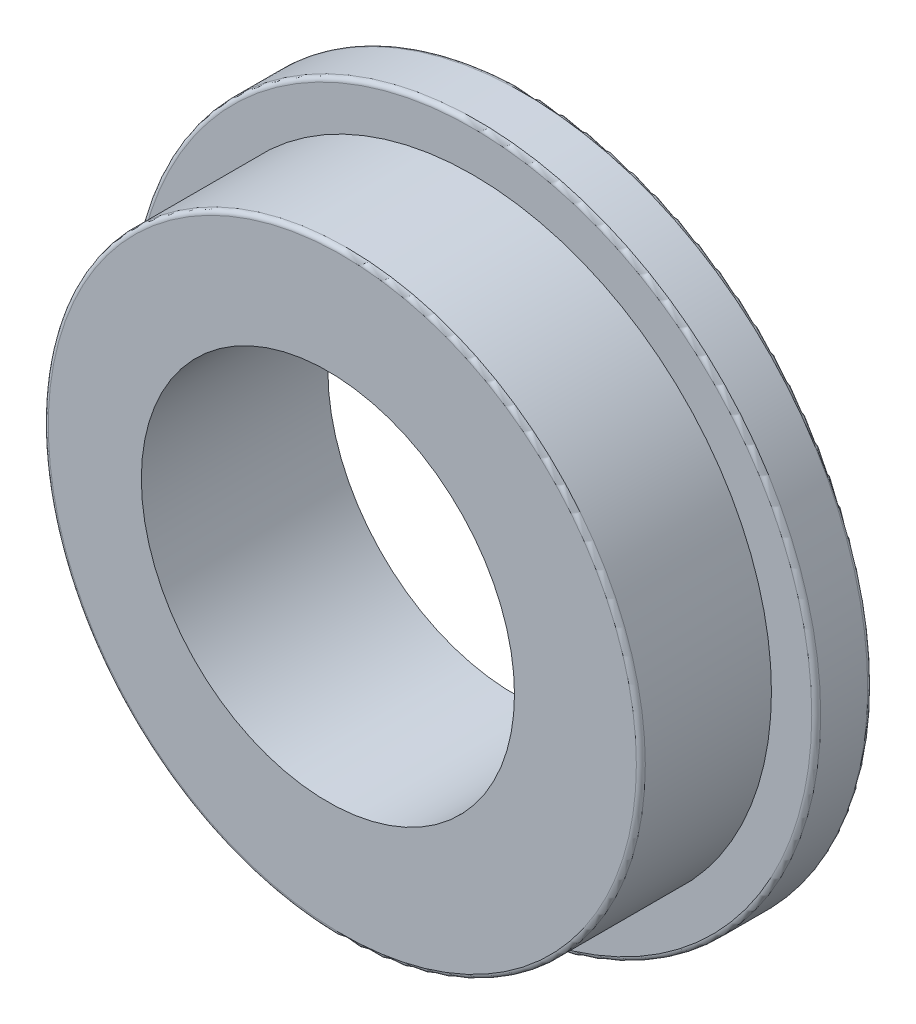
from build123d import *

# Parameters (mm, degrees)
SKETCH1_R           = 4.6
BOSS_EXTRUDE1_DEPTH = 0.75
SKETCH2_R           = 4
BOSS_EXTRUDE2_DEPTH = 1.75
SKETCH3_R           = 2.5
CUT_EXTRUDE1_DEPTH  = 3.5
FILLET1_R           = 0.06


with BuildPart() as part:
    # Sketch1 → Boss-Extrude1 (new body)
    with BuildSketch(Plane.XY):
        Circle(SKETCH1_R)
    extrude(amount=BOSS_EXTRUDE1_DEPTH)

    # Sketch2 → Boss-Extrude2 (add)
    with BuildSketch(Plane.XY.offset(0.75)):
        Circle(SKETCH2_R)
    extrude(amount=BOSS_EXTRUDE2_DEPTH)

    # Sketch3 → Cut-Extrude1 (cut, through all)
    with BuildSketch(Plane.XY.offset(2.5)):
        with Locations((-0.193142298, 0)):
            Circle(SKETCH3_R)
    extrude(amount=-CUT_EXTRUDE1_DEPTH, mode=Mode.SUBTRACT)

    # Fillet1
    fillet1_edges = [part.edges().sort_by_distance(p)[0] for p in [
        (-4.6, 0, 0),
        (-4.6, 0, 0.75),
        (-4, 0, 2.5),
    ]]
    fillet(fillet1_edges, radius=FILLET1_R)


solid = part.part
